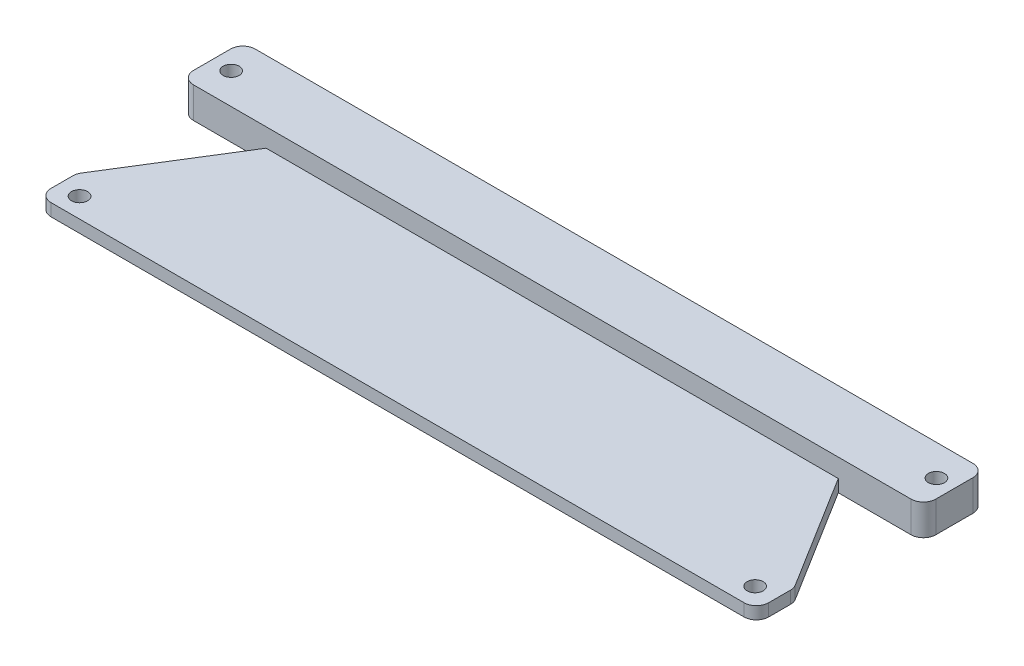
from build123d import *

# Parameters (mm, degrees)
SKETCH1_W           = 152.4
SKETCH1_H           = 12.7
EXTRUDE_THIN1_DEPTH = 6.35
FILLET1_R           = 2.54
SKETCH3_R           = 1.651
CUT_EXTRUDE1_DEPTH  = 6.35
LPATTERN1_COUNT     = 2
LPATTERN1_PITCH     = 144.78
SKETCH4_W           = 147.32
SKETCH4_H           = 2.54
EXTRUDE_THIN2_DEPTH = 31.75
CUT_EXTRUDE2_DEPTH  = 2.54
FILLET2_R           = 2.54
SKETCH7_R           = 1.651
CUT_EXTRUDE3_DEPTH  = 2.54


with BuildPart() as part:
    # Sketch1 → Extrude-Thin1 (new body)
    with BuildSketch(Plane(origin=(0, 0, 0), x_dir=(1, 0, 0), z_dir=(0, 1, 0))):
        with Locations((0, -6.35)):
            Rectangle(SKETCH1_W, SKETCH1_H)
    extrude(amount=EXTRUDE_THIN1_DEPTH)

    # Fillet1
    fillet1_edges = [part.edges().sort_by_distance(p)[0] for p in [
        (-76.2, 3.175, 12.7),
        (-76.2, 3.175, 0),
        (76.2, 3.175, 0),
        (76.2, 3.175, 12.7),
    ]]
    fillet(fillet1_edges, radius=FILLET1_R)

    # Sketch3 → Cut-Extrude1 (cut)
    with BuildSketch(Plane(origin=(0, 6.35, 0), x_dir=(1, 0, 0), z_dir=(0, 1, 0))):
        with Locations((72.520050335, -6.35)):
            Circle(SKETCH3_R)
    cut_extrude1 = extrude(amount=-CUT_EXTRUDE1_DEPTH, mode=Mode.SUBTRACT)

    # LPattern1: Cut-Extrude1 ×2
    with Locations(*[(-i * LPATTERN1_PITCH, 0, 0) for i in range(1, LPATTERN1_COUNT)]):
        add(cut_extrude1, mode=Mode.SUBTRACT)

    # Sketch4 → Extrude-Thin2 (add)
    with BuildSketch(Plane.XY.offset(12.7)):
        with Locations((0, 1.27)):
            Rectangle(SKETCH4_W, SKETCH4_H)
    extrude(amount=EXTRUDE_THIN2_DEPTH)

    # Sketch5 → Cut-Extrude2 (cut)
    with BuildSketch(Plane(origin=(0, 0, 0), x_dir=(-1, 0, 0), z_dir=(0, -1, 0))):
        Polygon((-73.66, -12.7), (-58.727381013, -12.7), (-73.66, -36.704605771), align=None)
    cut_extrude2 = extrude(amount=-CUT_EXTRUDE2_DEPTH, mode=Mode.SUBTRACT)

    # Mirror1: Cut-Extrude2 across plane
    add(cut_extrude2.mirror(Plane(origin=(0, 0, 0), x_dir=(0, 0, 1), z_dir=(1, 0, 0))), mode=Mode.SUBTRACT)

    # Fillet2
    fillet2_edges = [part.edges().sort_by_distance(p)[0] for p in [
        (-73.66, 1.27, 36.704605771),
        (73.66, 1.27, 44.45),
        (-73.66, 1.27, 44.45),
        (73.66, 1.27, 36.704605771),
    ]]
    fillet(fillet2_edges, radius=FILLET2_R)

    # Sketch7 → Cut-Extrude3 (cut)
    with BuildSketch(Plane(origin=(0, 2.54, 0), x_dir=(1, 0, 0), z_dir=(0, 1, 0))):
        with Locations((-69.342, -40.386)):
            Circle(SKETCH7_R)
    cut_extrude3 = extrude(amount=-CUT_EXTRUDE3_DEPTH, mode=Mode.SUBTRACT)

    # Mirror2: Cut-Extrude3 across plane
    add(cut_extrude3.mirror(Plane(origin=(0, 0, 0), x_dir=(0, 0, 1), z_dir=(1, 0, 0))), mode=Mode.SUBTRACT)


solid = part.part
